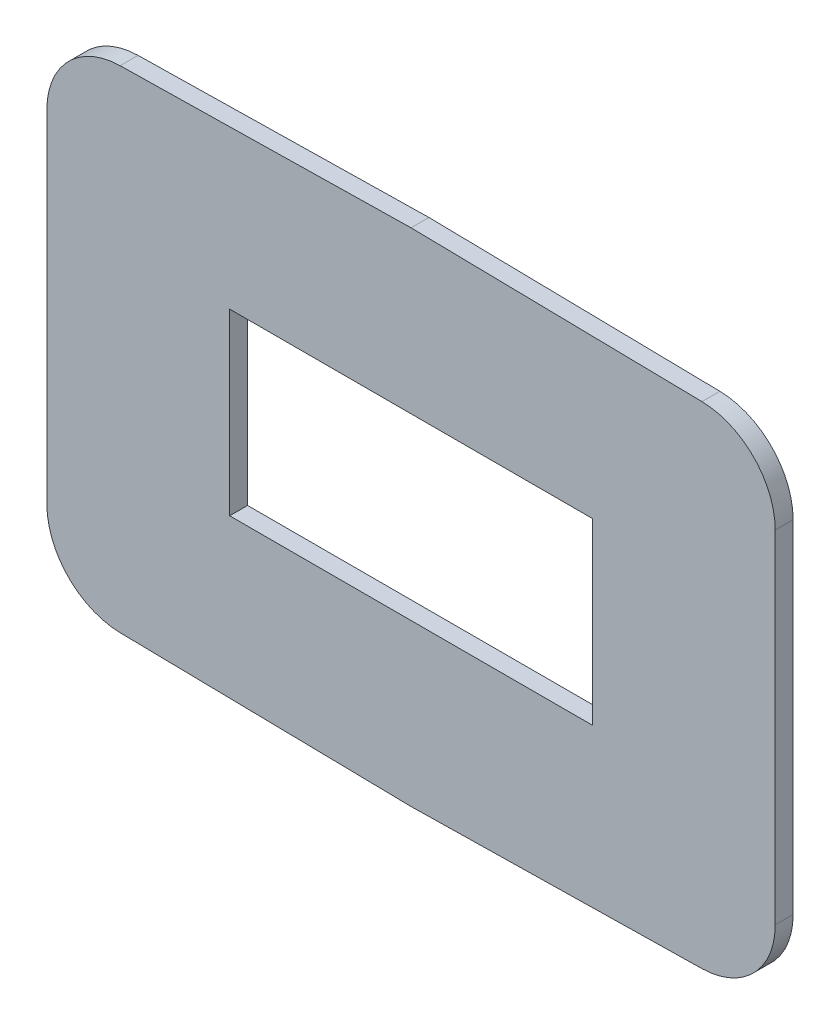
from build123d import *

# Parameters (mm, degrees)
SKETCH1_W      = 15.4432
SKETCH1_H      = 7.62
EXTRUDE1_DEPTH = 0.762
FILLET1_R      = 3.175


with BuildPart() as part:
    # Sketch1 → Extrude1 (new body)
    with BuildSketch(Plane.XY):
        Polygon((3.709668038, 4.91810583), (-11.793104343, 5.188707728), (-27.295876724, 4.91810583), (-27.295876724, -15.876690374), (-11.793104343, -16.147292272), (3.709668038, -15.876690374), align=None)
        with Locations((-11.793104343, -5.479292272)):
            Rectangle(SKETCH1_W, SKETCH1_H, mode=Mode.SUBTRACT)
    extrude(amount=EXTRUDE1_DEPTH)

    # Fillet1
    fillet1_edges = [part.edges().sort_by_distance(p)[0] for p in [
        (3.709668038, -15.876690374, 0.381),
        (-27.295876724, -15.876690374, 0.381),
        (-27.295876724, 4.91810583, 0.381),
        (3.709668038, 4.91810583, 0.381),
    ]]
    fillet(fillet1_edges, radius=FILLET1_R)


solid = part.part
